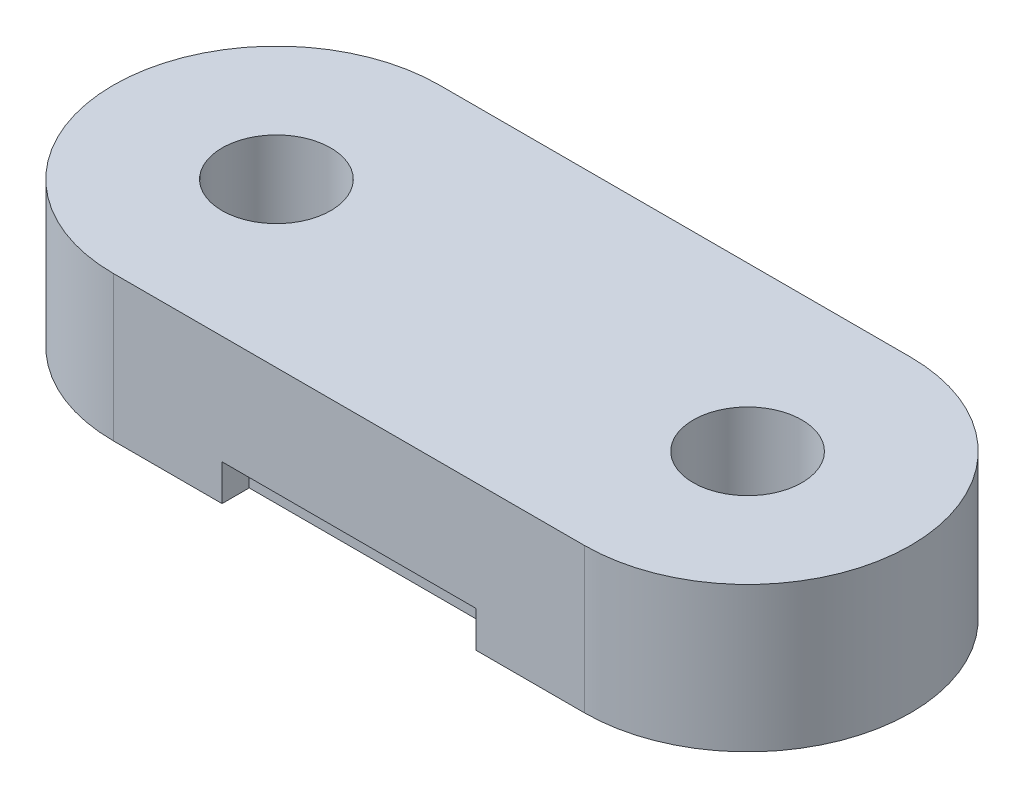
from build123d import *

# Parameters (mm, degrees)
SKETCH1_R      = 1.5
EXTRUDE1_DEPTH = 4
SKETCH2_W      = 7
SKETCH2_H      = 0.75
SKETCH2_H_2    = 1.5
EXTRUDE4_DEPTH = 1


with BuildPart() as part:
    # Sketch1 → Extrude1 (new body)
    with BuildSketch(Plane(origin=(0, 0, 0), x_dir=(1, 0, 0), z_dir=(0, 1, 0))):
        with BuildLine():
            Line((-6.5, 4.5), (6.5, 4.5))
            ThreePointArc((6.5, 4.5), (11, 0), (6.5, -4.5))
            Line((6.5, -4.5), (-6.5, -4.5))
            ThreePointArc((-6.5, -4.5), (-11, 0), (-6.5, 4.5))
        make_face()
        with Locations((6.5, 0)):
            Circle(SKETCH1_R, mode=Mode.SUBTRACT)
        with Locations((-6.5, 0)):
            Circle(SKETCH1_R, mode=Mode.SUBTRACT)
    extrude(amount=EXTRUDE1_DEPTH)

    # Sketch2 → Extrude4 (cut)
    with BuildSketch(Plane.XZ):
        with Locations((0, -4.125)):
            Rectangle(SKETCH2_W, SKETCH2_H)
        with Locations((0, -1.5)):
            Rectangle(SKETCH2_W, SKETCH2_H_2)
        with Locations((0, 1.5)):
            Rectangle(SKETCH2_W, SKETCH2_H_2)
        with Locations((0, 4.125)):
            Rectangle(SKETCH2_W, SKETCH2_H)
    extrude(amount=-EXTRUDE4_DEPTH, mode=Mode.SUBTRACT)


solid = part.part
